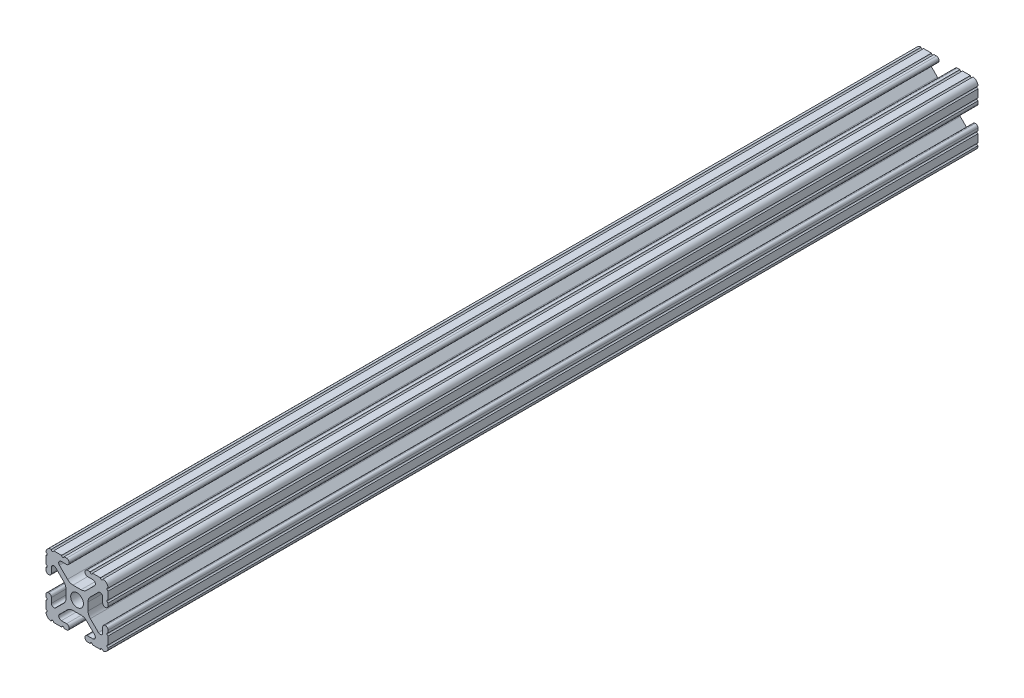
from build123d import *

# Parameters (mm, degrees)
SKETCH1_R           = 2.6035
BOSS_EXTRUDE1_DEPTH = 177.9


with BuildPart() as part:
    # Sketch1 → Boss-Extrude1 (new body, symmetric)
    with BuildSketch(Plane.XY):
        with BuildLine():
            Line((-7.179650497, -8.645192506), (-3.952270251, -5.423690499))
            ThreePointArc((-3.952270251, -5.423690499), (-2.922936451, -4.736929036), (-1.709253557, -4.4958))
            Line((-1.709253557, -4.4958), (1.709253557, -4.4958))
            ThreePointArc((1.709253557, -4.4958), (2.922936451, -4.736929036), (3.952270251, -5.423690499))
            Line((3.952270251, -5.423690499), (7.179650497, -8.645192506))
            ThreePointArc((7.179650497, -8.645192506), (7.41473083, -9.822813117), (6.416408329, -10.4902))
            Line((6.416408329, -10.4902), (4.287512407, -10.4902))
            ThreePointArc((4.287512407, -10.4902), (3.54574862, -10.79744862), (3.2385, -11.539212407))
            Line((3.2385, -11.539212407), (3.2385, -11.650987593))
            ThreePointArc((3.2385, -11.650987593), (3.54574862, -12.39275138), (4.287512407, -12.7))
            Line((4.287512407, -12.7), (5.317126718, -12.7))
            ThreePointArc((5.317126718, -12.7), (5.825126718, -12.192), (6.333126718, -12.7))
            Line((6.333126718, -12.7), (9.550443118, -12.7))
            ThreePointArc((9.550443118, -12.7), (10.058366869, -12.192000006), (10.566443095, -12.699847501))
            ThreePointArc((10.566443095, -12.699847501), (12.082537762, -12.08250727), (12.699846982, -10.566399977))
            ThreePointArc((12.699846982, -10.566399977), (12.192000006, -10.058323491), (12.7, -9.5504))
            Line((12.7, -9.5504), (12.7, -6.3330836))
            ThreePointArc((12.7, -6.3330836), (12.192, -5.8250836), (12.7, -5.3170836))
            Line((12.7, -5.3170836), (12.7, -4.287469289))
            ThreePointArc((12.7, -4.287469289), (12.39275138, -3.545705502), (11.650987593, -3.238456882))
            Line((11.650987593, -3.238456882), (11.539212407, -3.238456882))
            ThreePointArc((11.539212407, -3.238456882), (10.79744862, -3.545705502), (10.4902, -4.287469289))
            Line((10.4902, -4.287469289), (10.4902, -6.402089023))
            ThreePointArc((10.4902, -6.402089023), (9.856505071, -7.351067942), (8.737131347, -7.129408934))
            Line((8.737131347, -7.129408934), (5.441005833, -3.840816462))
            ThreePointArc((5.441005833, -3.840816462), (4.750877967, -2.809883091), (4.5085, -1.593185507))
            Line((4.5085, -1.593185507), (4.5085, 1.593185507))
            ThreePointArc((4.5085, 1.593185507), (4.750877967, 2.809883091), (5.441005833, 3.840816462))
            Line((5.441005833, 3.840816462), (8.737131347, 7.129408934))
            ThreePointArc((8.737131347, 7.129408934), (9.856505071, 7.351067942), (10.4902, 6.402089023))
            Line((10.4902, 6.402089023), (10.4902, 4.287469289))
            ThreePointArc((10.4902, 4.287469289), (10.79744862, 3.545705502), (11.539212407, 3.238456882))
            Line((11.539212407, 3.238456882), (11.650987593, 3.238456882))
            ThreePointArc((11.650987593, 3.238456882), (12.39275138, 3.545705502), (12.7, 4.287469289))
            Line((12.7, 4.287469289), (12.7, 5.3170836))
            ThreePointArc((12.7, 5.3170836), (12.192, 5.8250836), (12.7, 6.3330836))
            Line((12.7, 6.3330836), (12.7, 9.5504))
            ThreePointArc((12.7, 9.5504), (12.192000006, 10.058323491), (12.699846982, 10.566399977))
            ThreePointArc((12.699846982, 10.566399977), (12.082537762, 12.08250727), (10.566443095, 12.699847501))
            ThreePointArc((10.566443095, 12.699847501), (10.058366869, 12.192000006), (9.550443118, 12.7))
            Line((9.550443118, 12.7), (6.333126718, 12.7))
            ThreePointArc((6.333126718, 12.7), (5.825126718, 12.192), (5.317126718, 12.7))
            Line((5.317126718, 12.7), (4.287512407, 12.7))
            ThreePointArc((4.287512407, 12.7), (3.54574862, 12.39275138), (3.2385, 11.650987593))
            Line((3.2385, 11.650987593), (3.2385, 11.539212407))
            ThreePointArc((3.2385, 11.539212407), (3.54574862, 10.79744862), (4.287512407, 10.4902))
            Line((4.287512407, 10.4902), (6.476788598, 10.4902))
            ThreePointArc((6.476788598, 10.4902), (7.432222385, 9.85140422), (7.207036008, 8.724370562))
            Line((7.207036008, 8.724370562), (3.898272566, 5.423169045))
            ThreePointArc((3.898272566, 5.423169045), (2.869120213, 4.736787962), (1.655778399, 4.4958))
            Line((1.655778399, 4.4958), (-1.655778399, 4.4958))
            ThreePointArc((-1.655778399, 4.4958), (-2.869120213, 4.736787962), (-3.898272566, 5.423169045))
            Line((-3.898272566, 5.423169045), (-7.207036008, 8.724370562))
            ThreePointArc((-7.207036008, 8.724370562), (-7.432222385, 9.85140422), (-6.476788598, 10.4902))
            Line((-6.476788598, 10.4902), (-4.287512407, 10.4902))
            ThreePointArc((-4.287512407, 10.4902), (-3.54574862, 10.79744862), (-3.2385, 11.539212407))
            Line((-3.2385, 11.539212407), (-3.2385, 11.650987593))
            ThreePointArc((-3.2385, 11.650987593), (-3.54574862, 12.39275138), (-4.287512407, 12.7))
            Line((-4.287512407, 12.7), (-5.317126718, 12.7))
            ThreePointArc((-5.317126718, 12.7), (-5.825126718, 12.192), (-6.333126718, 12.7))
            Line((-6.333126718, 12.7), (-9.550443118, 12.7))
            ThreePointArc((-9.550443118, 12.7), (-10.058366869, 12.192000006), (-10.566443095, 12.699847501))
            ThreePointArc((-10.566443095, 12.699847501), (-12.082537762, 12.08250727), (-12.699846982, 10.566399977))
            ThreePointArc((-12.699846982, 10.566399977), (-12.192000006, 10.058323491), (-12.7, 9.5504))
            Line((-12.7, 9.5504), (-12.7, 6.3330836))
            ThreePointArc((-12.7, 6.3330836), (-12.192, 5.8250836), (-12.7, 5.3170836))
            Line((-12.7, 5.3170836), (-12.7, 4.287469289))
            ThreePointArc((-12.7, 4.287469289), (-12.39275138, 3.545705502), (-11.650987593, 3.238456882))
            Line((-11.650987593, 3.238456882), (-11.539212407, 3.238456882))
            ThreePointArc((-11.539212407, 3.238456882), (-10.79744862, 3.545705502), (-10.4902, 4.287469289))
            Line((-10.4902, 4.287469289), (-10.4902, 6.402089023))
            ThreePointArc((-10.4902, 6.402089023), (-9.856505071, 7.351067942), (-8.737131347, 7.129408934))
            Line((-8.737131347, 7.129408934), (-5.441005833, 3.840816462))
            ThreePointArc((-5.441005833, 3.840816462), (-4.750877967, 2.809883091), (-4.5085, 1.593185507))
            Line((-4.5085, 1.593185507), (-4.5085, -1.593185507))
            ThreePointArc((-4.5085, -1.593185507), (-4.750877967, -2.809883091), (-5.441005833, -3.840816462))
            Line((-5.441005833, -3.840816462), (-8.737131347, -7.129408934))
            ThreePointArc((-8.737131347, -7.129408934), (-9.856505071, -7.351067942), (-10.4902, -6.402089023))
            Line((-10.4902, -6.402089023), (-10.4902, -4.287469289))
            ThreePointArc((-10.4902, -4.287469289), (-10.79744862, -3.545705502), (-11.539212407, -3.238456882))
            Line((-11.539212407, -3.238456882), (-11.650987593, -3.238456882))
            ThreePointArc((-11.650987593, -3.238456882), (-12.39275138, -3.545705502), (-12.7, -4.287469289))
            Line((-12.7, -4.287469289), (-12.7, -5.3170836))
            ThreePointArc((-12.7, -5.3170836), (-12.192, -5.8250836), (-12.7, -6.3330836))
            Line((-12.7, -6.3330836), (-12.7, -9.5504))
            ThreePointArc((-12.7, -9.5504), (-12.192000006, -10.058323491), (-12.699846982, -10.566399977))
            ThreePointArc((-12.699846982, -10.566399977), (-12.082537762, -12.08250727), (-10.566443095, -12.699847501))
            ThreePointArc((-10.566443095, -12.699847501), (-10.058366869, -12.192000006), (-9.550443118, -12.7))
            Line((-9.550443118, -12.7), (-6.333126718, -12.7))
            ThreePointArc((-6.333126718, -12.7), (-5.825126718, -12.192), (-5.317126718, -12.7))
            Line((-5.317126718, -12.7), (-4.287512407, -12.7))
            ThreePointArc((-4.287512407, -12.7), (-3.54574862, -12.39275138), (-3.2385, -11.650987593))
            Line((-3.2385, -11.650987593), (-3.2385, -11.539212407))
            ThreePointArc((-3.2385, -11.539212407), (-3.54574862, -10.79744862), (-4.287512407, -10.4902))
            Line((-4.287512407, -10.4902), (-6.416408329, -10.4902))
            ThreePointArc((-6.416408329, -10.4902), (-7.41473083, -9.822813117), (-7.179650497, -8.645192506))
        make_face()
        Circle(SKETCH1_R, mode=Mode.SUBTRACT)
    extrude(amount=BOSS_EXTRUDE1_DEPTH, both=True)


solid = part.part
